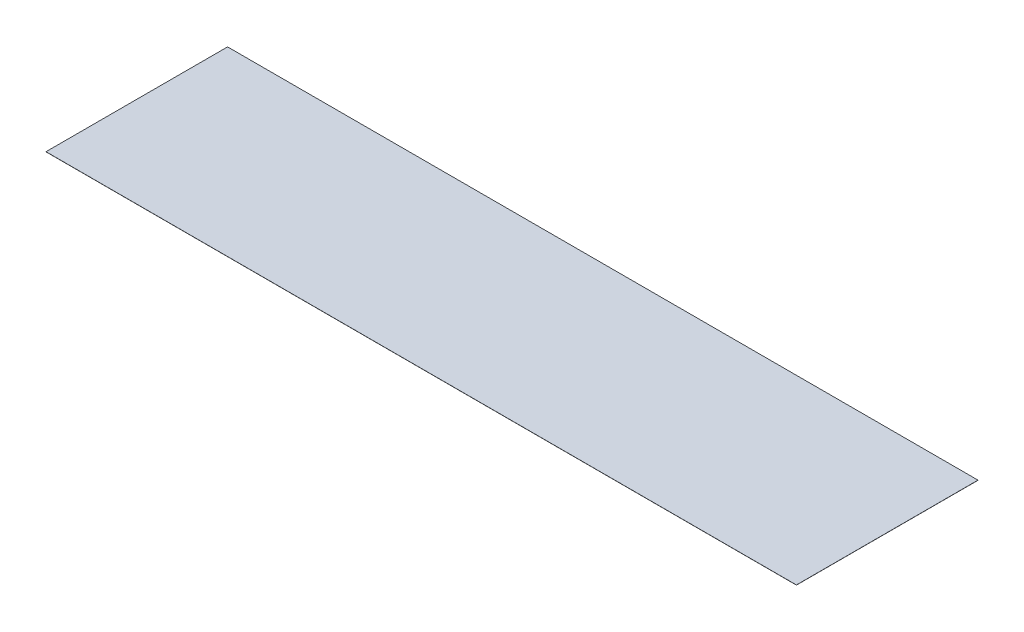
from build123d import *

# Parameters (mm, degrees)
SKETCH1_W           = 5038.860755395
SKETCH1_H           = 1219.2
BOSS_EXTRUDE1_DEPTH = 1


with BuildPart() as part:
    # Sketch1 → Boss-Extrude1 (new body)
    with BuildSketch(Plane(origin=(0, 0, 0), x_dir=(1, 0, 0), z_dir=(0, 1, 0))):
        with Locations((2519.430377698, 609.6)):
            Rectangle(SKETCH1_W, SKETCH1_H)
    extrude(amount=BOSS_EXTRUDE1_DEPTH)


solid = part.part
